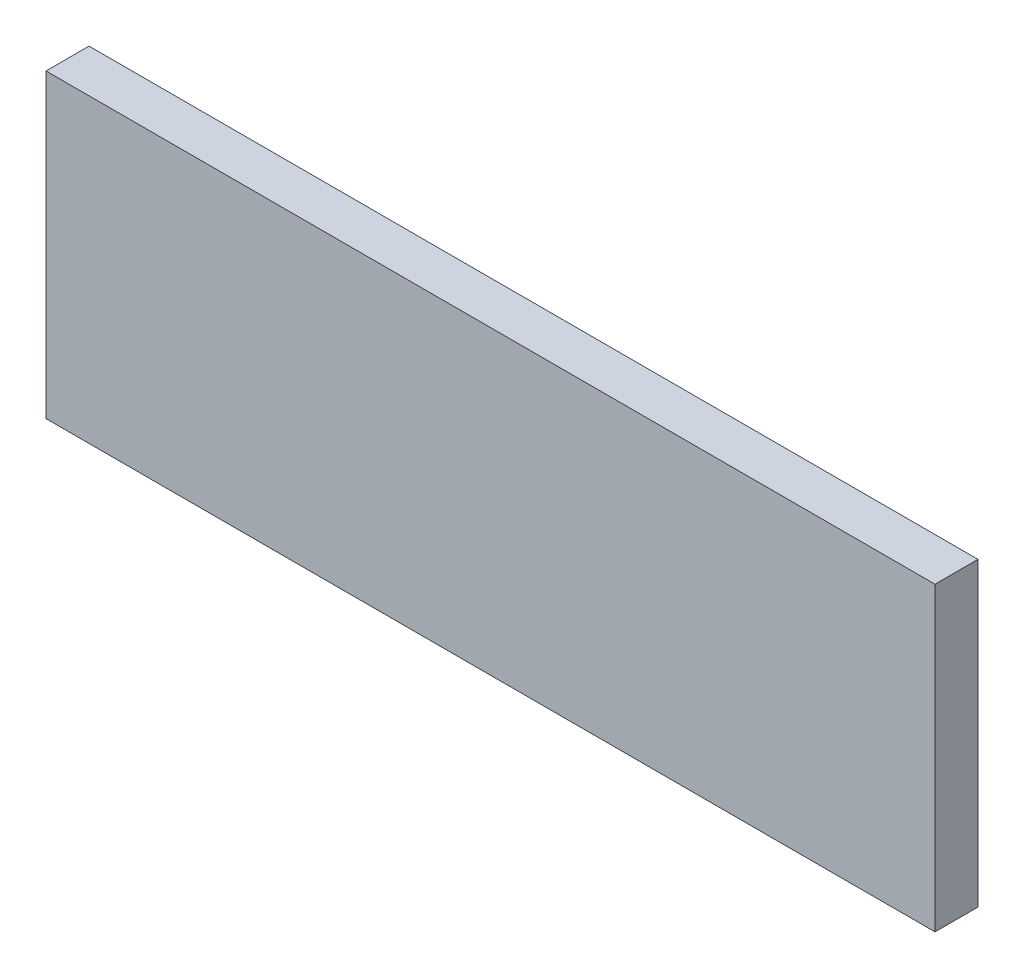
from build123d import *

# Parameters (mm, degrees)
ESQUISSE1_W        = 31
ESQUISSE1_H        = 10.5
BOSS_EXTRU_1_DEPTH = 0.75


with BuildPart() as part:
    # Esquisse1 → Boss.-Extru.1 (new body, symmetric)
    with BuildSketch(Plane.XY):
        Rectangle(ESQUISSE1_W, ESQUISSE1_H)
    extrude(amount=BOSS_EXTRU_1_DEPTH, both=True)


solid = part.part
